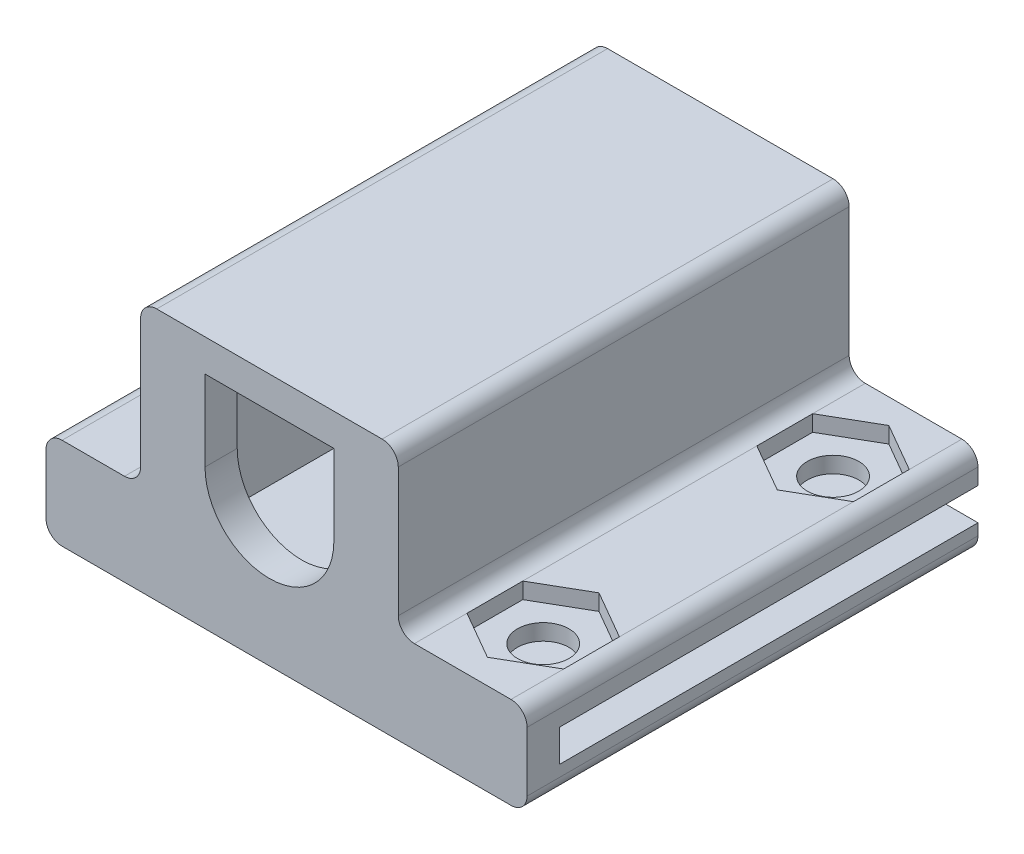
from build123d import *

# Parameters (mm, degrees)
EXTRUDE_1_DEPTH          = 2
EXTRUDE_2_DEPTH          = 26
CUT_EXTRUDE_2_DEPTH      = 11
CUT_EXTRUDE_2_DEPTH_BACK = 1
CUT_EXTRUDE_3_DEPTH      = 11
CUT_EXTRUDE_3_DEPTH_BACK = 1
SKETCH_9_R               = 1.6
CUT_EXTRUDE_4_DEPTH      = 5.7
SKETCH_10_W              = 12
SKETCH_10_H              = 1
EXTRUDE_3_DEPTH          = 1.6


with BuildPart() as part:
    # 草图1 → 凸台-拉伸1 (new body)
    with BuildSketch(Plane.XY):
        with BuildLine():
            ThreePointArc((16, -4), (15.707106781, -3.292893219), (15, -3))
            Line((15, -3), (9, -3))
            ThreePointArc((9, -3), (8.292893219, -2.707106781), (8, -2))
            Line((8, -2), (8, 6))
            ThreePointArc((8, 6), (7.707106781, 6.707106781), (7, 7))
            Line((7, 7), (-7, 7))
            ThreePointArc((-7, 7), (-7.707106781, 6.707106781), (-8, 6))
            Line((-8, 6), (-8, -2))
            ThreePointArc((-8, -2), (-8.292893219, -2.707106781), (-9, -3))
            Line((-9, -3), (-12.875, -3))
            ThreePointArc((-12.875, -3), (-13.582106781, -3.292893219), (-13.875, -4))
            Line((-13.875, -4), (-13.875, -7.7))
            ThreePointArc((-13.875, -7.7), (-13.582106781, -8.407106781), (-12.875, -8.7))
            Line((-12.875, -8.7), (15, -8.7))
            ThreePointArc((15, -8.7), (15.707106781, -8.407106781), (16, -7.7))
            Line((16, -7.7), (16, -4))
        make_face()
        with BuildLine():
            Line((4, 5), (4, 0))
            ThreePointArc((4, 0), (0, -4), (-4, 0))
            Line((-4, 0), (-4, 5))
            Line((-4, 5), (4, 5))
        make_face(mode=Mode.SUBTRACT)
    extrude(amount=EXTRUDE_1_DEPTH)

    # 草图2 → 凸台-拉伸2 (add)
    with BuildSketch(Plane(origin=(0, 0, 0), x_dir=(-1, 0, 0), z_dir=(0, 0, -1))):
        with BuildLine():
            Line((-6, 4.5), (-6, 5))
            Line((-6, 5), (-5.5, 5))
            Line((-5.5, 5), (5.5, 5))
            Line((5.5, 5), (6, 5))
            Line((6, 5), (6, 4.5))
            Line((6, 4.5), (6, -4.5))
            Line((6, -4.5), (6, -5))
            Line((6, -5), (11.875, -5))
            Line((11.875, -5), (11.875, -7))
            Line((11.875, -7), (-16, -7))
            Line((-16, -7), (-16, -7.7))
            ThreePointArc((-16, -7.7), (-15.707106781, -8.407106781), (-15, -8.7))
            Line((-15, -8.7), (12.875, -8.7))
            ThreePointArc((12.875, -8.7), (13.582106781, -8.407106781), (13.875, -7.7))
            Line((13.875, -7.7), (13.875, -4))
            ThreePointArc((13.875, -4), (13.582106781, -3.292893219), (12.875, -3))
            Line((12.875, -3), (9, -3))
            ThreePointArc((9, -3), (8.292893219, -2.707106781), (8, -2))
            Line((8, -2), (8, 6))
            ThreePointArc((8, 6), (7.707106781, 6.707106781), (7, 7))
            Line((7, 7), (-7, 7))
            ThreePointArc((-7, 7), (-7.707106781, 6.707106781), (-8, 6))
            Line((-8, 6), (-8, -2))
            ThreePointArc((-8, -2), (-8.292893219, -2.707106781), (-9, -3))
            Line((-9, -3), (-15, -3))
            ThreePointArc((-15, -3), (-15.707106781, -3.292893219), (-16, -4))
            Line((-16, -4), (-16, -5))
            Line((-16, -5), (-6, -5))
            Line((-6, -5), (-6, -4.5))
            Line((-6, -4.5), (-6, 4.5))
        make_face()
    extrude(amount=EXTRUDE_2_DEPTH)

    # 草图5 → 切除-拉伸2 (cut, two sides)
    with BuildSketch(Plane(origin=(0, -3, 0), x_dir=(1, 0, 0), z_dir=(0, 1, 0))) as cut_extrude_2_sk:
        Polygon((15, 22.732050808), (12, 24.464101615), (9, 22.732050808), (9, 19.267949192), (12, 17.535898385), (15, 19.267949192), align=None)
    extrude(amount=CUT_EXTRUDE_2_DEPTH, mode=Mode.SUBTRACT)
    extrude(cut_extrude_2_sk.sketch, amount=-CUT_EXTRUDE_2_DEPTH_BACK, mode=Mode.SUBTRACT)

    # 草图6 → 切除-拉伸3 (cut, two sides)
    with BuildSketch(Plane(origin=(0, -3, 0), x_dir=(1, 0, 0), z_dir=(0, 1, 0))) as cut_extrude_3_sk:
        Polygon((15, 4.732050808), (12, 6.464101615), (9, 4.732050808), (9, 1.267949192), (12, -0.464101615), (15, 1.267949192), align=None)
    extrude(amount=CUT_EXTRUDE_3_DEPTH, mode=Mode.SUBTRACT)
    extrude(cut_extrude_3_sk.sketch, amount=-CUT_EXTRUDE_3_DEPTH_BACK, mode=Mode.SUBTRACT)

    # 草图9 → 切除-拉伸4 (cut, through all)
    with BuildSketch(Plane(origin=(0, -4, 0), x_dir=(1, 0, 0), z_dir=(0, 1, 0))):
        with Locations((12, 3)):
            Circle(SKETCH_9_R)
        with Locations((12, 21)):
            Circle(SKETCH_9_R)
    extrude(amount=-CUT_EXTRUDE_4_DEPTH, mode=Mode.SUBTRACT)


with BuildPart() as body_2:
    # 草图10 → 凸台-拉伸3 (new body)
    with BuildSketch(Plane(origin=(0, 0, -26), x_dir=(-1, 0, 0), z_dir=(0, 0, -1))):
        with Locations((0, 4.5)):
            Rectangle(SKETCH_10_W, SKETCH_10_H)
    extrude(amount=-EXTRUDE_3_DEPTH)


solid = Compound([part.part, body_2.part])
